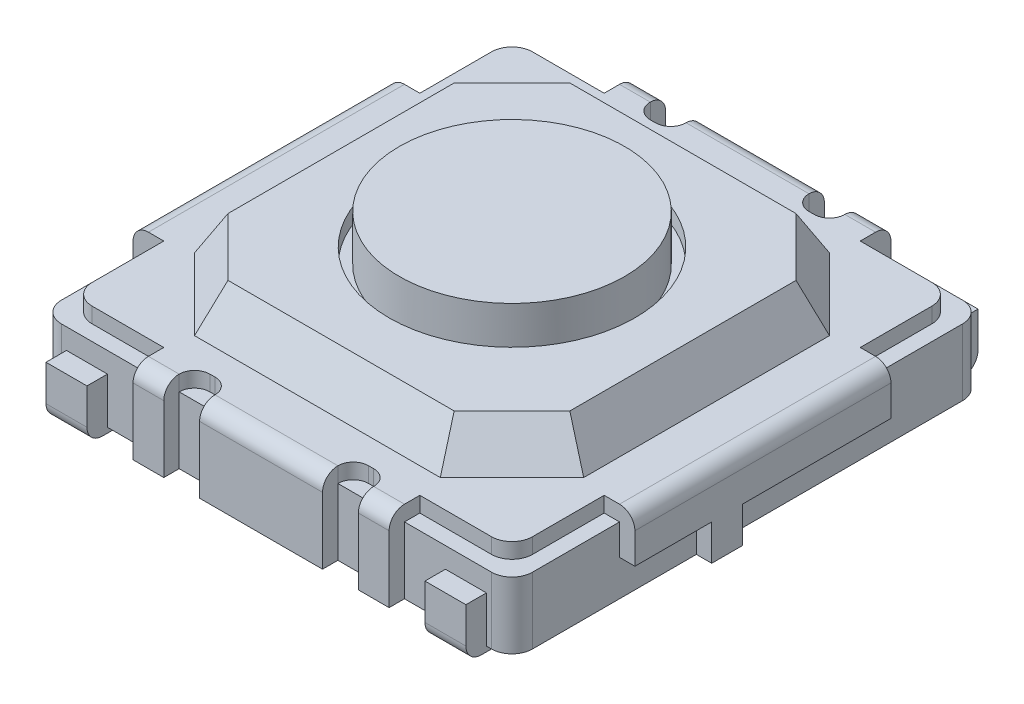
from build123d import *

# Parameters (mm, degrees)
SKETCH1_W           = 4.6
SKETCH1_H           = 4.6
EXTRUDE1_DEPTH      = 0.65
EXTRUDE2_DEPTH      = 0.8
EXTRUDE3_DEPTH      = 0.4
EXTRUDE3_TAPER      = 30
SKETCH1_4_R         = 1.1
EXTRUDE4_DEPTH      = 1.5
CUT_EXTRUDE1_START  = -0.15
SKETCH3_R           = 1.2
SKETCH3_R_2         = 1.1
CUT_EXTRUDE1_DEPTH  = 0.15
SKETCH4_W           = 0.75
SKETCH4_H           = 0.35
SKETCH4_W_2         = 1.45
CUT_EXTRUDE2_DEPTH  = 0.15
SKETCH5_W           = 0.75
SKETCH5_H           = 0.35
SKETCH5_W_2         = 1.45
CUT_EXTRUDE3_DEPTH  = 0.15
EXTRUDE5_DEPTH      = 0.45
EXTRUDE5_DEPTH_BACK = 0.05
FILLET1_R           = 0.2
FILLET2_R           = 0.15
FILLET3_R           = 0.15


with BuildPart() as part:
    # Sketch1 → Extrude1 (new body)
    with BuildSketch(Plane(origin=(0, 0, 0), x_dir=(1, 0, 0), z_dir=(0, 1, 0))):
        Rectangle(SKETCH1_W, SKETCH1_H)
    extrude(amount=EXTRUDE1_DEPTH)

    # Sketch1_3 → Extrude2 (add)
    with BuildSketch(Plane(origin=(0, 0, 0), x_dir=(1, 0, 0), z_dir=(0, 1, 0))):
        Polygon((-2.45, 1.25), (-2.45, -1.25), (-2.15, -1.25), (-2.15, -2.15), (-1.25, -2.15), (-1.25, -2.45), (-0.95, -2.45), (-0.95, -2.15), (-0.6, -2.15), (-0.6, -2.45), (0.6, -2.45), (0.6, -2.15), (0.95, -2.15), (0.95, -2.45), (1.25, -2.45), (1.25, -2.15), (2.15, -2.15), (2.15, -1.25), (2.45, -1.25), (2.45, 1.25), (2.15, 1.25), (2.15, 2.15), (1.25, 2.15), (1.25, 2.45), (0.95, 2.45), (0.95, 2.15), (0.6, 2.15), (0.6, 2.45), (-0.6, 2.45), (-0.6, 2.15), (-0.95, 2.15), (-0.95, 2.45), (-1.25, 2.45), (-1.25, 2.15), (-2.15, 2.15), (-2.15, 1.25), align=None)
    extrude(amount=EXTRUDE2_DEPTH)

    # Sketch2 → Extrude3 (add)
    with BuildSketch(Plane(origin=(0, 0.8, 0), x_dir=(-1, 0, 0), z_dir=(0, 1, 0))):
        Polygon((1.9, 1.2), (1.2, 1.9), (-1.2, 1.9), (-1.9, 1.2), (-1.9, -1.2), (-1.2, -1.9), (1.2, -1.9), (1.9, -1.2), align=None)
    extrude(amount=EXTRUDE3_DEPTH, taper=EXTRUDE3_TAPER)

    # Sketch1_4 → Extrude4 (add)
    with BuildSketch(Plane(origin=(0, 0, 0), x_dir=(1, 0, 0), z_dir=(0, 1, 0))):
        Circle(SKETCH1_4_R)
    extrude(amount=EXTRUDE4_DEPTH)

    # Sketch3 → Cut-Extrude1 (cut)
    with BuildSketch(Plane(origin=(0, 1.2, 0), x_dir=(-1, 0, 0), z_dir=(0, 1, 0)).offset(CUT_EXTRUDE1_START)):
        Circle(SKETCH3_R)
        Circle(SKETCH3_R_2, mode=Mode.SUBTRACT)
    extrude(amount=CUT_EXTRUDE1_DEPTH, mode=Mode.SUBTRACT)

    # Sketch4 → Cut-Extrude2 (cut)
    with BuildSketch(Plane(origin=(2.45, 0, 0), x_dir=(0, 0, -1), z_dir=(1, 0, 0))):
        with Locations((-0.875, 0.175)):
            Rectangle(SKETCH4_W, SKETCH4_H)
        with Locations((0.525, 0.175)):
            Rectangle(SKETCH4_W_2, SKETCH4_H)
    extrude(amount=-CUT_EXTRUDE2_DEPTH, mode=Mode.SUBTRACT)

    # Sketch5 → Cut-Extrude3 (cut)
    with BuildSketch(Plane.ZY.offset(2.45)):
        with Locations((-0.875, 0.175)):
            Rectangle(SKETCH5_W, SKETCH5_H)
        with Locations((0.525, 0.175)):
            Rectangle(SKETCH5_W_2, SKETCH5_H)
    extrude(amount=-CUT_EXTRUDE3_DEPTH, mode=Mode.SUBTRACT)

    # Sketch6 → Extrude5 (add, two sides: drawn at the far end of the back side and taken through both)
    with BuildSketch(Plane(origin=(0, 0, 0), x_dir=(1, 0, 0), z_dir=(0, 1, 0)).offset(-EXTRUDE5_DEPTH_BACK)):
        Polygon((2.05, 2.5), (1.85, 2.5), (1.65, 2.5), (1.65, 1.75), (2.05, 1.75), align=None)
        Polygon((-2.05, 2.5), (-1.85, 2.5), (-1.65, 2.5), (-1.65, 1.75), (-2.05, 1.75), align=None)
        Polygon((2.05, -2.5), (1.85, -2.5), (1.65, -2.5), (1.65, -1.75), (2.05, -1.75), align=None)
        Polygon((-1.85, -2.5), (-1.65, -2.5), (-1.65, -1.75), (-2.05, -1.75), (-2.05, -2.5), align=None)
    extrude(amount=EXTRUDE5_DEPTH + EXTRUDE5_DEPTH_BACK)

    # Fillet1
    fillet1_edges = [part.edges().sort_by_distance(p)[0] for p in [
        (-2.15, 0.725, -2.15),
        (-2.3, 0.325, -2.3),
        (2.15, 0.725, -2.15),
        (2.3, 0.325, -2.3),
        (2.15, 0.725, 2.15),
        (2.3, 0.325, 2.3),
        (-2.15, 0.725, 2.15),
        (-2.3, 0.325, 2.3),
    ]]
    fillet(fillet1_edges, radius=FILLET1_R)

    # Fillet2
    fillet2_edges = [part.edges().sort_by_distance(p)[0] for p in [
        (0.95, 0.725, 2.15),
        (0.6, 0.725, 2.15),
        (-0.6, 0.725, 2.15),
        (-0.95, 0.725, 2.15),
        (-0.95, 0.725, -2.15),
        (-0.6, 0.725, -2.15),
        (0.6, 0.725, -2.15),
        (0.95, 0.725, -2.15),
    ]]
    fillet(fillet2_edges, radius=FILLET2_R)

    # Fillet3
    fillet3_edges = [part.edges().sort_by_distance(p)[0] for p in [
        (1.85, -0.05, 2.5),
        (-1.85, -0.05, 2.5),
        (1.85, -0.05, -2.5),
        (-1.85, -0.05, -2.5),
        (-2.45, 0.8, 0),
        (-1.1, 0.8, -2.45),
        (0, 0.8, -2.45),
        (1.1, 0.8, -2.45),
        (2.45, 0.8, 0),
        (1.1, 0.8, 2.45),
        (-1.1, 0.8, 2.45),
        (0, 0.8, 2.45),
    ]]
    fillet(fillet3_edges, radius=FILLET3_R)


solid = part.part
